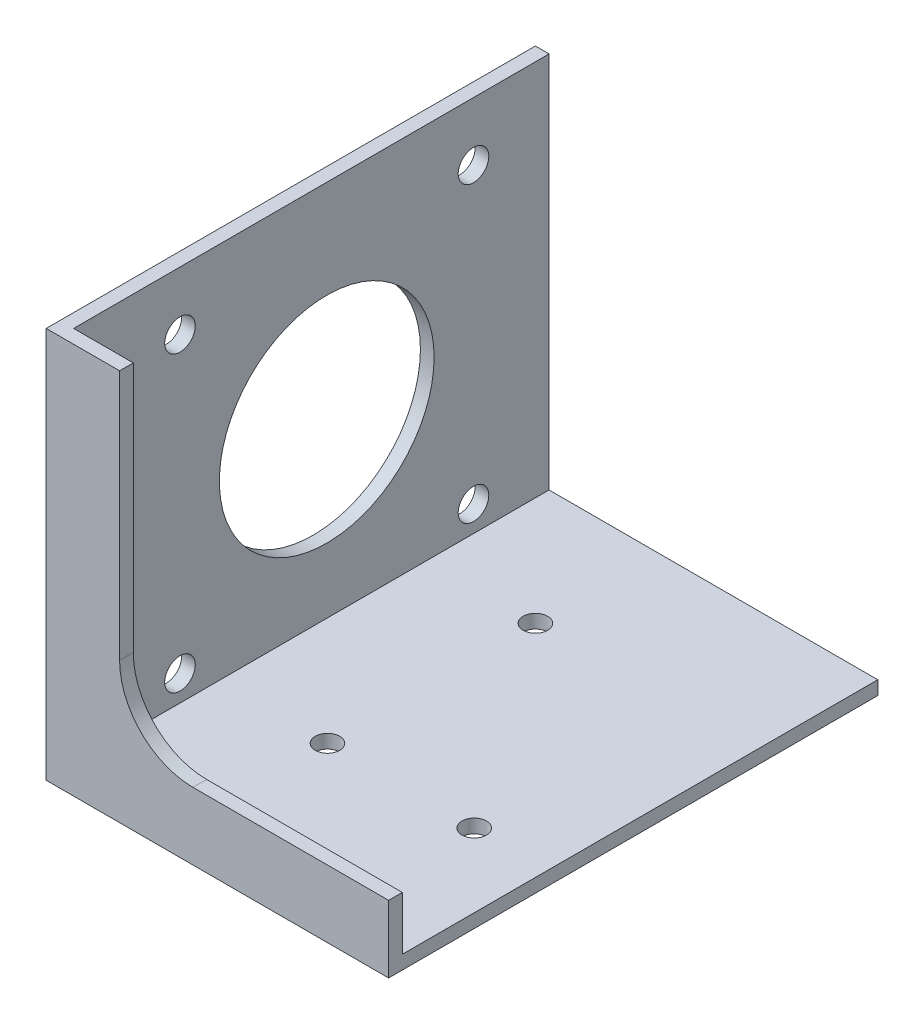
from build123d import *

# Parameters (mm, degrees)
SKETCH1_W           = 35.56
SKETCH1_H           = 50.8
BOSS_EXTRUDE1_DEPTH = 20.32
SKETCH2_W           = 49.3776
SKETCH2_H           = 39.2176
CUT_EXTRUDE1_DEPTH  = 34.1376
SKETCH3_R           = 1.27
CUT_EXTRUDE2_DEPTH  = 2.4224
CUT_EXTRUDE3_DEPTH  = 2.4224
SKETCH7_R           = 11.1506
SKETCH7_R_2         = 1.5875
CUT_EXTRUDE4_DEPTH  = 2.4224


with BuildPart() as part:
    # Sketch1 → Boss-Extrude1 (new body, symmetric)
    with BuildSketch(Plane(origin=(0, 0, 0), x_dir=(1, 0, 0), z_dir=(0, 1, 0))):
        Rectangle(SKETCH1_W, SKETCH1_H)
    extrude(amount=BOSS_EXTRUDE1_DEPTH, both=True)

    # Sketch2 → Cut-Extrude1 (cut)
    with BuildSketch(Plane(origin=(17.78, 0, 0), x_dir=(0, 0, -1), z_dir=(1, 0, 0))):
        with Locations((0.7112, 0.7112)):
            Rectangle(SKETCH2_W, SKETCH2_H)
    extrude(amount=-CUT_EXTRUDE1_DEPTH, mode=Mode.SUBTRACT)

    # Sketch3 → Cut-Extrude2 (cut, through all)
    with BuildSketch(Plane(origin=(0, -18.8976, 0), x_dir=(1, 0, 0), z_dir=(0, 1, 0))):
        with Locations((-5.08, -8.89)):
            Circle(SKETCH3_R)
        with Locations((10.16, -8.89)):
            Circle(SKETCH3_R)
        with Locations((-5.08, 12.7)):
            Circle(SKETCH3_R)
    extrude(amount=-CUT_EXTRUDE2_DEPTH, mode=Mode.SUBTRACT)

    # Sketch6 → Cut-Extrude3 (cut, through all)
    with BuildSketch(Plane(origin=(0, 0, 23.9776), x_dir=(-1, 0, 0), z_dir=(0, 0, -1))):
        with BuildLine():
            Line((-17.78, -13.335), (-17.78, 20.32))
            Line((-17.78, 20.32), (10.16, 20.32))
            Line((10.16, 20.32), (10.16, -5.715))
            ThreePointArc((10.16, -5.715), (7.928153673, -11.103153673), (2.54, -13.335))
            Line((2.54, -13.335), (-17.78, -13.335))
        make_face()
    extrude(amount=-CUT_EXTRUDE3_DEPTH, mode=Mode.SUBTRACT)

    # Sketch7 → Cut-Extrude4 (cut, through all)
    with BuildSketch(Plane(origin=(-16.3576, 0, 0), x_dir=(0, 0, -1), z_dir=(1, 0, 0))):
        with Locations((2.3114, -0.9906)):
            Circle(SKETCH7_R)
        with Locations((-12.9286, 14.2494)):
            Circle(SKETCH7_R_2)
        with Locations((17.5514, 14.2494)):
            Circle(SKETCH7_R_2)
        with Locations((17.5514, -16.2306)):
            Circle(SKETCH7_R_2)
        with Locations((-12.9286, -16.2306)):
            Circle(SKETCH7_R_2)
    extrude(amount=-CUT_EXTRUDE4_DEPTH, mode=Mode.SUBTRACT)


solid = part.part
